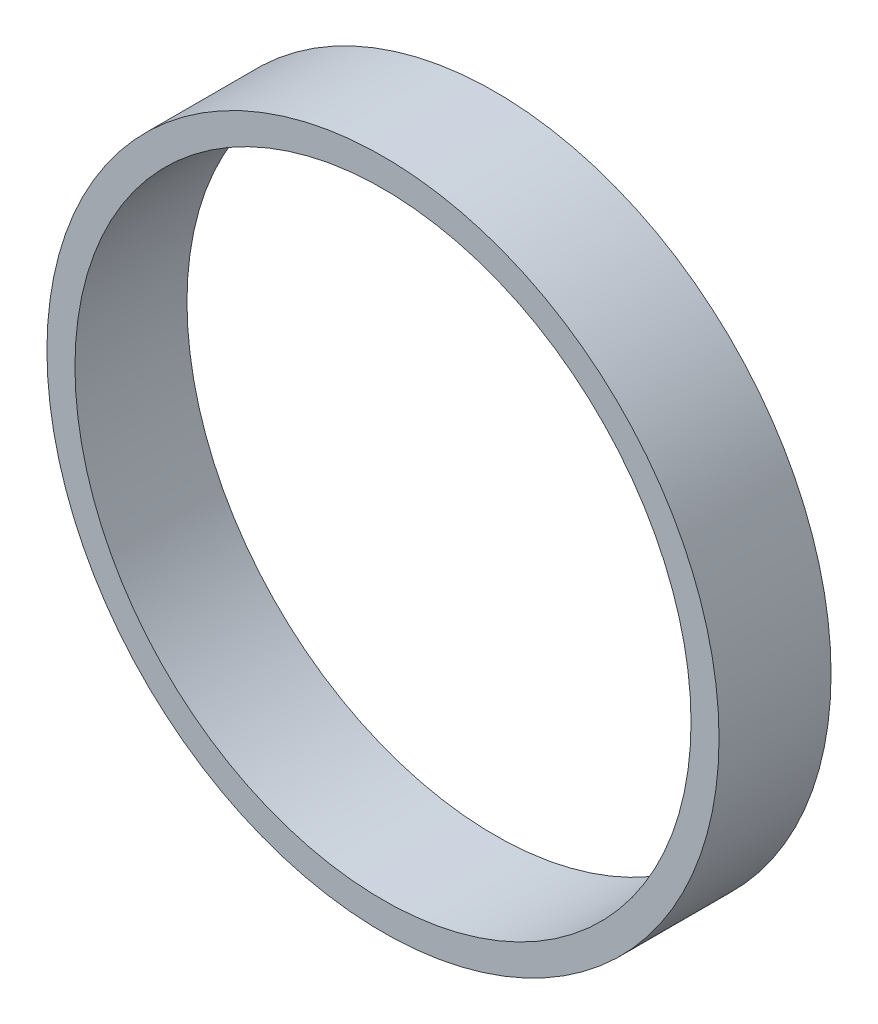
from build123d import *

# Parameters (mm, degrees)
SKETCH_1_R      = 30
SKETCH_1_R_2    = 27.5
EXTRUDE_1_DEPTH = 10


with BuildPart() as part:
    # 草图1 → 凸台-拉伸1 (new body)
    with BuildSketch(Plane.XY):
        Circle(SKETCH_1_R)
        Circle(SKETCH_1_R_2, mode=Mode.SUBTRACT)
    extrude(amount=EXTRUDE_1_DEPTH)


solid = part.part
